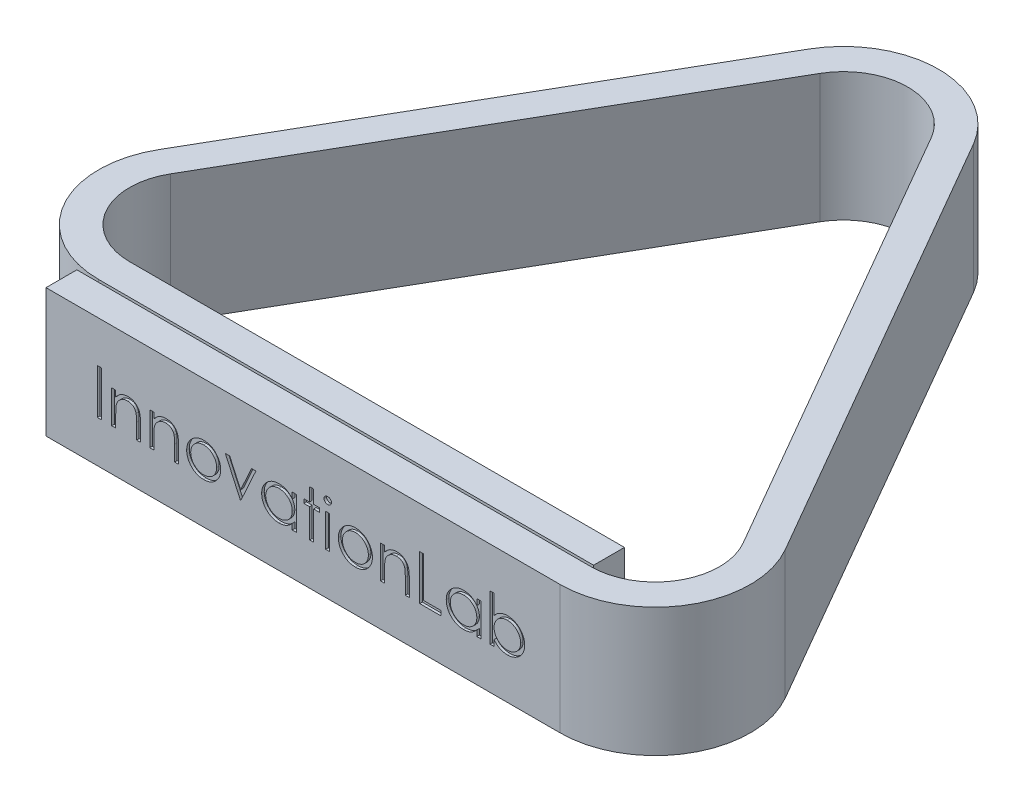
from build123d import *

# Parameters (mm, degrees)
BOSS_EXTRU_1_DEPTH      = 10
ESQUISSE2_W             = 0.314102564
ESQUISSE2_H             = 3.5
ESQUISSE2_H_2           = 2.557692307
ENL_V_MAT_EXTRU_1_DEPTH = 0.2


with BuildPart() as part:
    # Esquisse1 → Boss.-Extru.1 (new body)
    with BuildSketch(Plane(origin=(0, 0, 0), x_dir=(1, 0, 0), z_dir=(0, 1, 0))):
        with BuildLine():
            Line((0, 0), (40, 0))
            ThreePointArc((40, 0), (44.330127019, 2.5), (44.330127019, 7.5))
            Line((44.330127019, 7.5), (24.330127019, 42.141016151))
            ThreePointArc((24.330127019, 42.141016151), (20, 44.641016151), (15.669872981, 42.141016151))
            Line((15.669872981, 42.141016151), (-2.829016319, 10.1))
            ThreePointArc((-2.829016319, 10.1), (-2.829016319, 5.1), (1.5011107, 2.6))
            Line((1.5011107, 2.6), (40, 2.6))
            Line((40, 2.6), (40, 0.2))
            Line((40, 0.2), (1.5011107, 0.2))
            ThreePointArc((1.5011107, 0.2), (-4.907477288, 3.9), (-4.907477288, 11.3))
            Line((-4.907477288, 11.3), (13.591412012, 43.341016151))
            ThreePointArc((13.591412012, 43.341016151), (20, 47.041016151), (26.408587988, 43.341016151))
            Line((26.408587988, 43.341016151), (46.408587988, 8.7))
            ThreePointArc((46.408587988, 8.7), (46.408587988, 1.3), (40, -2.4))
            Line((40, -2.4), (0, -2.4))
            Line((0, -2.4), (0, 0))
        make_face()
    extrude(amount=BOSS_EXTRU_1_DEPTH)

    # Esquisse2 → Enlèv. mat.-Extru.1 (cut)
    with BuildSketch(Plane.XY.offset(2.4)):
        with Locations((4.146183367, 5.001354305)):
            Rectangle(ESQUISSE2_W, ESQUISSE2_H)
        with BuildLine():
            Line((5.110926957, 5.809046612), (5.425029521, 5.809046612))
            Line((5.425029521, 5.809046612), (5.425029521, 5.347708471))
            add(Edge.make_bspline(
                [(5.425029521, 5.347708471), (5.458567156, 5.389551194), (5.523648107, 5.470748458), (5.63203244, 5.577469032), (5.746576341, 5.665414257), (5.866578344, 5.735518051), (5.992201354, 5.788364677), (6.122679624, 5.826530609), (6.25879433, 5.849415437), (6.351358767, 5.852405667), (6.398186572, 5.853918407)],
                knots=[0, 0, 0, 0, 0.000160777, 0.000311994, 0.000455029, 0.000592958, 0.000727738, 0.000862858, 0.001000022, 0.001140458, 0.001140458, 0.001140458, 0.001140458], degree=3))
            add(Edge.make_bspline(
                [(6.398186572, 5.853918407), (6.445517206, 5.852173212), (6.538154674, 5.848757443), (6.673032735, 5.821740752), (6.799006129, 5.775595497), (6.915625685, 5.712383427), (7.020752898, 5.633776953), (7.11307775, 5.542199172), (7.189440997, 5.436863088), (7.24063836, 5.339139932), (7.274364008, 5.252451138), (7.295596345, 5.178204388), (7.313627327, 5.095486237), (7.329259075, 5.004546648), (7.339836187, 4.904748457), (7.348178478, 4.796500765), (7.354157172, 4.679838635), (7.354394379, 4.599152007), (7.3545167, 4.557544209)],
                knots=[0, 0, 0, 0, 0.00014192, 0.000277771, 0.000410631, 0.000543023, 0.000674273, 0.000803173, 0.000931629, 0.001063031, 0.00113295, 0.001210382, 0.001294414, 0.001386856, 0.001487045, 0.001595345, 0.001712567, 0.001837375, 0.001837375, 0.001837375, 0.001837375], degree=3))
            Line((7.3545167, 4.557544209), (7.3545167, 3.251354305))
            Line((7.3545167, 3.251354305), (7.040414136, 3.251354305))
            Line((7.040414136, 3.251354305), (7.040414136, 4.454479305))
            add(Edge.make_bspline(
                [(7.040414136, 4.454479305), (7.040220928, 4.48930175), (7.039851354, 4.55591116), (7.038685707, 4.651280184), (7.035875901, 4.737766762), (7.031927588, 4.815164129), (7.026148557, 4.883397966), (7.020125926, 4.942607243), (7.012760949, 4.992716785), (7.006198036, 5.022881868), (7.003254681, 5.036410394)],
                knots=[0, 0, 0, 0, 0.00010447, 0.000199832, 0.000286116, 0.000364054, 0.000432294, 0.000491525, 0.000542592, 0.000584118, 0.000584118, 0.000584118, 0.000584118], degree=3))
            add(Edge.make_bspline(
                [(7.003254681, 5.036410394), (6.99262915, 5.076121579), (6.972178289, 5.152553324), (6.921644306, 5.256227677), (6.857830125, 5.344425865), (6.779932276, 5.416602586), (6.6887032, 5.472773423), (6.584396057, 5.511747378), (6.468017417, 5.536123647), (6.386163034, 5.538550779), (6.343499072, 5.539815843)],
                knots=[0, 0, 0, 0, 0.000123096, 0.000236922, 0.000343781, 0.000447968, 0.000553428, 0.000663063, 0.000780492, 0.000908329, 0.000908329, 0.000908329, 0.000908329], degree=3))
            add(Edge.make_bspline(
                [(6.343499072, 5.539815843), (6.318231389, 5.539339839), (6.268227296, 5.538397838), (6.194077324, 5.52894654), (6.12215315, 5.513488084), (6.051732941, 5.492619446), (5.984225148, 5.463957177), (5.917460857, 5.431427807), (5.853954092, 5.390879595), (5.792350695, 5.345688974), (5.735037888, 5.295609766), (5.681709549, 5.242765256), (5.634171529, 5.186489652), (5.591102854, 5.127689705), (5.55392459, 5.065557867), (5.521471502, 5.00069356), (5.493935807, 4.933011412), (5.480253115, 4.88603635), (5.473406925, 4.862532189)],
                knots=[0, 0, 0, 0, 7.5773e-05, 0.000149953, 0.000223797, 0.000296325, 0.00036989, 0.000443574, 0.000518859, 0.000595564, 0.000672601, 0.000746967, 0.000820581, 0.000893366, 0.000965391, 0.001037508, 0.001110807, 0.001184211, 0.001184211, 0.001184211, 0.001184211], degree=3))
            add(Edge.make_bspline(
                [(5.473406925, 4.862532189), (5.469467276, 4.845276986), (5.460890867, 4.807713312), (5.451627687, 4.746068893), (5.443220112, 4.674758918), (5.436183153, 4.5938666), (5.431877737, 4.503108725), (5.42718334, 4.402872888), (5.425474279, 4.292759399), (5.425181925, 4.216097706), (5.425029521, 4.176133952)],
                knots=[0, 0, 0, 0, 5.3082e-05, 0.000115557, 0.000186868, 0.0002685, 0.000359077, 0.000459426, 0.000569522, 0.000689416, 0.000689416, 0.000689416, 0.000689416], degree=3))
            Line((5.425029521, 4.176133952), (5.425029521, 3.251354305))
            Line((5.425029521, 3.251354305), (5.110926957, 3.251354305))
            Line((5.110926957, 3.251354305), (5.110926957, 5.809046612))
        make_face()
        with BuildLine():
            Line((8.072465418, 5.809046612), (8.386567982, 5.809046612))
            Line((8.386567982, 5.809046612), (8.386567982, 5.347708471))
            add(Edge.make_bspline(
                [(8.386567982, 5.347708471), (8.420105618, 5.389551194), (8.485186569, 5.470748458), (8.593570902, 5.577469032), (8.708114802, 5.665414257), (8.828116806, 5.735518051), (8.953739816, 5.788364677), (9.084218086, 5.826530609), (9.220332792, 5.849415437), (9.312897229, 5.852405667), (9.359725034, 5.853918407)],
                knots=[0, 0, 0, 0, 0.000160777, 0.000311994, 0.000455029, 0.000592958, 0.000727738, 0.000862858, 0.001000022, 0.001140458, 0.001140458, 0.001140458, 0.001140458], degree=3))
            add(Edge.make_bspline(
                [(9.359725034, 5.853918407), (9.407055668, 5.852173212), (9.499693136, 5.848757443), (9.634571197, 5.821740752), (9.760544591, 5.775595497), (9.877164146, 5.712383427), (9.98229136, 5.633776953), (10.074616211, 5.542199172), (10.150979459, 5.436863088), (10.202176822, 5.339139932), (10.235902469, 5.252451138), (10.257134807, 5.178204388), (10.275165788, 5.095486237), (10.290797536, 5.004546648), (10.301374648, 4.904748457), (10.30971694, 4.796500765), (10.315695634, 4.679838635), (10.315932841, 4.599152007), (10.316055162, 4.557544209)],
                knots=[0, 0, 0, 0, 0.00014192, 0.000277771, 0.000410631, 0.000543023, 0.000674273, 0.000803173, 0.000931629, 0.001063031, 0.00113295, 0.001210382, 0.001294414, 0.001386856, 0.001487045, 0.001595345, 0.001712567, 0.001837375, 0.001837375, 0.001837375, 0.001837375], degree=3))
            Line((10.316055162, 4.557544209), (10.316055162, 3.251354305))
            Line((10.316055162, 3.251354305), (10.001952598, 3.251354305))
            Line((10.001952598, 3.251354305), (10.001952598, 4.454479305))
            add(Edge.make_bspline(
                [(10.001952598, 4.454479305), (10.00175939, 4.48930175), (10.001389816, 4.55591116), (10.000224169, 4.651280184), (9.997414362, 4.737766762), (9.99346605, 4.815164129), (9.987687019, 4.883397966), (9.981664388, 4.942607243), (9.974299411, 4.992716785), (9.967736498, 5.022881868), (9.964793143, 5.036410394)],
                knots=[0, 0, 0, 0, 0.00010447, 0.000199832, 0.000286116, 0.000364054, 0.000432294, 0.000491525, 0.000542592, 0.000584118, 0.000584118, 0.000584118, 0.000584118], degree=3))
            add(Edge.make_bspline(
                [(9.964793143, 5.036410394), (9.954167611, 5.076121579), (9.93371675, 5.152553324), (9.883182767, 5.256227677), (9.819368587, 5.344425865), (9.741470737, 5.416602586), (9.650241662, 5.472773423), (9.545934519, 5.511747378), (9.429555878, 5.536123647), (9.347701495, 5.538550779), (9.305037534, 5.539815843)],
                knots=[0, 0, 0, 0, 0.000123096, 0.000236922, 0.000343781, 0.000447968, 0.000553428, 0.000663063, 0.000780492, 0.000908329, 0.000908329, 0.000908329, 0.000908329], degree=3))
            add(Edge.make_bspline(
                [(9.305037534, 5.539815843), (9.27976985, 5.539339839), (9.229765757, 5.538397838), (9.155615785, 5.52894654), (9.083691612, 5.513488084), (9.013271403, 5.492619446), (8.945763609, 5.463957177), (8.878999318, 5.431427807), (8.815492554, 5.390879595), (8.753889157, 5.345688974), (8.696576349, 5.295609766), (8.643248011, 5.242765256), (8.595709991, 5.186489652), (8.552641315, 5.127689705), (8.515463052, 5.065557867), (8.483009964, 5.00069356), (8.455474269, 4.933011412), (8.441791577, 4.88603635), (8.434945386, 4.862532189)],
                knots=[0, 0, 0, 0, 7.5773e-05, 0.000149953, 0.000223797, 0.000296325, 0.00036989, 0.000443574, 0.000518859, 0.000595564, 0.000672601, 0.000746967, 0.000820581, 0.000893366, 0.000965391, 0.001037508, 0.001110807, 0.001184211, 0.001184211, 0.001184211, 0.001184211], degree=3))
            add(Edge.make_bspline(
                [(8.434945386, 4.862532189), (8.431005738, 4.845276986), (8.422429329, 4.807713312), (8.413166149, 4.746068893), (8.404758574, 4.674758918), (8.397721615, 4.5938666), (8.393416198, 4.503108725), (8.388721802, 4.402872888), (8.387012741, 4.292759399), (8.386720387, 4.216097706), (8.386567982, 4.176133952)],
                knots=[0, 0, 0, 0, 5.3082e-05, 0.000115557, 0.000186868, 0.0002685, 0.000359077, 0.000459426, 0.000569522, 0.000689416, 0.000689416, 0.000689416, 0.000689416], degree=3))
            Line((8.386567982, 4.176133952), (8.386567982, 3.251354305))
            Line((8.386567982, 3.251354305), (8.072465418, 3.251354305))
            Line((8.072465418, 3.251354305), (8.072465418, 5.809046612))
        make_face()
        with BuildLine():
            add(Edge.make_bspline(
                [(12.269380482, 5.853918407), (12.317371755, 5.852896516), (12.411470913, 5.850892837), (12.549278799, 5.829477872), (12.680823935, 5.796730507), (12.806610127, 5.751458945), (12.925026422, 5.690776995), (13.037797666, 5.618367704), (13.144614675, 5.53258511), (13.208637704, 5.466227042), (13.24113529, 5.432544209)],
                knots=[0, 0, 0, 0, 0.000143868, 0.000282091, 0.000417278, 0.000550139, 0.000682145, 0.000815559, 0.000951665, 0.001091969, 0.001091969, 0.001091969, 0.001091969], degree=3))
            add(Edge.make_bspline(
                [(13.24113529, 5.432544209), (13.269117244, 5.400330223), (13.324539624, 5.336525681), (13.395605343, 5.233070068), (13.456826903, 5.125929967), (13.505889864, 5.01368264), (13.544574888, 4.897307969), (13.572040584, 4.776405958), (13.588377519, 4.651243611), (13.590580486, 4.566239773), (13.591696188, 4.523189241)],
                knots=[0, 0, 0, 0, 0.000127922, 0.000253368, 0.000375813, 0.000497617, 0.000620225, 0.000743195, 0.000869033, 0.000998161, 0.000998161, 0.000998161, 0.000998161], degree=3))
            add(Edge.make_bspline(
                [(13.591696188, 4.523189241), (13.59071485, 4.479889183), (13.588775682, 4.39432625), (13.570432066, 4.268306884), (13.54190098, 4.146112061), (13.501069141, 4.028253367), (13.448711032, 3.91437054), (13.384820345, 3.804960991), (13.308948728, 3.699808857), (13.222944731, 3.599807019), (13.127892855, 3.507640804), (13.024776706, 3.427312535), (12.915622673, 3.35849101), (12.798979319, 3.303054595), (12.675911832, 3.259344895), (12.546154764, 3.228644878), (12.409909694, 3.210083194), (12.316882473, 3.207699621), (12.269380482, 3.20648251)],
                knots=[0, 0, 0, 0, 0.000129829, 0.000256548, 0.000381202, 0.000505812, 0.000630045, 0.000756669, 0.000885282, 0.001018518, 0.001151902, 0.001281775, 0.001409974, 0.001538236, 0.001668405, 0.001801048, 0.001937587, 0.002080055, 0.002080055, 0.002080055, 0.002080055], degree=3))
            add(Edge.make_bspline(
                [(12.269380482, 3.20648251), (12.221645763, 3.207703706), (12.128154903, 3.210095481), (11.991428921, 3.228572763), (11.861439302, 3.259330746), (11.738210704, 3.303198239), (11.621065857, 3.358492782), (11.51127936, 3.427104472), (11.408079444, 3.507664627), (11.31300746, 3.599800564), (11.227008855, 3.699810521), (11.151135846, 3.804960559), (11.08724552, 3.914370652), (11.034887316, 4.028253337), (10.994055503, 4.146112069), (10.965524411, 4.268306882), (10.947180796, 4.39432625), (10.945241628, 4.479889183), (10.94426029, 4.523189241)],
                knots=[0, 0, 0, 0, 0.000143168, 0.000280402, 0.000413045, 0.000543214, 0.000672108, 0.000800903, 0.000930775, 0.00106416, 0.001197395, 0.001326009, 0.001452632, 0.001576866, 0.001701476, 0.00182613, 0.001952849, 0.002082678, 0.002082678, 0.002082678, 0.002082678], degree=3))
            add(Edge.make_bspline(
                [(10.94426029, 4.523189241), (10.9453836, 4.566005787), (10.947607562, 4.650775189), (10.963928071, 4.77570225), (10.991286627, 4.896399639), (11.030018024, 5.012325115), (11.079533215, 5.124080551), (11.139894503, 5.231485382), (11.211685135, 5.334473182), (11.266887087, 5.398195262), (11.294821188, 5.430440843)],
                knots=[0, 0, 0, 0, 0.000128428, 0.000254265, 0.000377235, 0.000499178, 0.000620341, 0.000743397, 0.000868267, 0.000996189, 0.000996189, 0.000996189, 0.000996189], degree=3))
            add(Edge.make_bspline(
                [(11.294821188, 5.430440843), (11.327269779, 5.464415782), (11.391085642, 5.531233479), (11.49843437, 5.616766003), (11.610928191, 5.690682077), (11.730653117, 5.750158292), (11.856335975, 5.79699681), (11.988555218, 5.829562325), (12.126830733, 5.85081568), (12.221390354, 5.852873858), (12.269380482, 5.853918407)],
                knots=[0, 0, 0, 0, 0.000140798, 0.000276904, 0.000410699, 0.000543958, 0.000677061, 0.000812248, 0.000951858, 0.001095726, 0.001095726, 0.001095726, 0.001095726], degree=3))
        make_face()
        with BuildLine():
            add(Edge.make_bspline(
                [(12.267978239, 5.539815843), (12.234040627, 5.538851252), (12.167041499, 5.536946969), (12.068421914, 5.522463064), (11.97348176, 5.49951556), (11.882040916, 5.466911504), (11.794407744, 5.424812605), (11.710498341, 5.373104245), (11.630065901, 5.312471288), (11.554683838, 5.243008617), (11.485501526, 5.167129622), (11.425023549, 5.086281263), (11.373598443, 5.001774917), (11.330758284, 4.913522706), (11.298851096, 4.820630292), (11.275678073, 4.724149661), (11.261207833, 4.623884244), (11.259321454, 4.555723226), (11.258362854, 4.521085875)],
                knots=[0, 0, 0, 0, 0.000101781, 0.000200935, 0.000298373, 0.000394396, 0.000491609, 0.000589491, 0.000689611, 0.000793323, 0.000896562, 0.000997243, 0.001095722, 0.001192936, 0.001290943, 0.001389744, 0.001490285, 0.001594167, 0.001594167, 0.001594167, 0.001594167], degree=3))
            add(Edge.make_bspline(
                [(11.258362854, 4.521085875), (11.259969678, 4.476333848), (11.263158922, 4.387509443), (11.289094159, 4.25669832), (11.332480439, 4.131116468), (11.391067718, 4.011500082), (11.464473937, 3.900827804), (11.550961004, 3.802156319), (11.649600704, 3.716970508), (11.759217204, 3.646289662), (11.877571522, 3.590129907), (12.002827843, 3.550330931), (12.133468537, 3.524459239), (12.222749268, 3.521887764), (12.267978239, 3.520585074)],
                knots=[0, 0, 0, 0, 0.000134178, 0.000266319, 0.000398243, 0.00053182, 0.000664828, 0.000795487, 0.000924236, 0.001054533, 0.001185628, 0.001316003, 0.001448011, 0.001583547, 0.001583547, 0.001583547, 0.001583547], degree=3))
            add(Edge.make_bspline(
                [(12.267978239, 3.520585074), (12.313204608, 3.521895354), (12.402480204, 3.524481811), (12.532939381, 3.550200631), (12.657853352, 3.590304292), (12.77608474, 3.646226501), (12.885651343, 3.717238916), (12.985000465, 3.801675293), (13.070749076, 3.901089145), (13.144082681, 4.011646673), (13.203629423, 4.130931026), (13.246812625, 4.256721498), (13.272810211, 4.38750354), (13.27599104, 4.47633187), (13.277593623, 4.521085875)],
                knots=[0, 0, 0, 0, 0.000135536, 0.000267545, 0.000397252, 0.000528347, 0.000658644, 0.000787925, 0.000918122, 0.00105113, 0.001185017, 0.001316942, 0.001449082, 0.00158326, 0.00158326, 0.00158326, 0.00158326], degree=3))
            add(Edge.make_bspline(
                [(13.277593623, 4.521085875), (13.276635353, 4.555723433), (13.274749624, 4.623884859), (13.26027466, 4.724147312), (13.23711912, 4.820638909), (13.205147503, 4.913490912), (13.162493489, 5.002003416), (13.110076696, 5.086033144), (13.049845671, 5.16740969), (12.97982855, 5.24276333), (12.904525172, 5.312498367), (12.824060134, 5.373127756), (12.740275155, 5.424585352), (12.652896572, 5.467271592), (12.561444005, 5.499218933), (12.466636876, 5.522595564), (12.368438066, 5.536885761), (12.301679023, 5.538832902), (12.267978239, 5.539815843)],
                knots=[0, 0, 0, 0, 0.000103882, 0.000204424, 0.000303225, 0.000401232, 0.000498445, 0.000597291, 0.000697972, 0.000801684, 0.000905395, 0.001005516, 0.001103397, 0.001199979, 0.001296663, 0.00139342, 0.001492573, 0.001593654, 0.001593654, 0.001593654, 0.001593654], degree=3))
        make_face(mode=Mode.SUBTRACT)
        Polygon((13.950670547, 5.809046612), (14.290714617, 5.809046612), (15.139773111, 3.946867125), (15.988831604, 5.809046612), (16.328875675, 5.809046612), (15.162209008, 3.251354305), (15.117337213, 3.251354305), align=None)
        with BuildLine():
            Line((19.469901316, 5.809046612), (19.469901316, 3.251354305))
            Line((19.469901316, 3.251354305), (19.155798752, 3.251354305))
            Line((19.155798752, 3.251354305), (19.155798752, 3.693762157))
            add(Edge.make_bspline(
                [(19.155798752, 3.693762157), (19.120379961, 3.653722563), (19.051259746, 3.575584792), (18.935818628, 3.47350262), (18.81345045, 3.389124298), (18.684749129, 3.320974383), (18.549830885, 3.269782326), (18.408994798, 3.233396167), (18.262183417, 3.210002332), (18.161931062, 3.20766631), (18.111127277, 3.20648251)],
                knots=[0, 0, 0, 0, 0.000160263, 0.000312755, 0.000460949, 0.000605216, 0.000748578, 0.000892786, 0.001041028, 0.001193333, 0.001193333, 0.001193333, 0.001193333], degree=3))
            add(Edge.make_bspline(
                [(18.111127277, 3.20648251), (18.065959323, 3.207708882), (17.976886119, 3.210127343), (17.845857041, 3.228889646), (17.719764792, 3.259020268), (17.598490219, 3.300921157), (17.482818074, 3.356501979), (17.371757977, 3.423043227), (17.265885285, 3.502284057), (17.166813746, 3.592872085), (17.075581746, 3.691267073), (16.995520473, 3.796212619), (16.928767393, 3.907254923), (16.872947313, 4.022988077), (16.829950968, 4.144302997), (16.799977334, 4.270780165), (16.781236887, 4.402270038), (16.778819427, 4.491809561), (16.777593623, 4.537211677)],
                knots=[0, 0, 0, 0, 0.000135464, 0.00026714, 0.000396211, 0.000523931, 0.000651257, 0.000780517, 0.000911767, 0.001047265, 0.00118272, 0.001313831, 0.001442491, 0.001570752, 0.001698704, 0.001827775, 0.001960146, 0.00209631, 0.00209631, 0.00209631, 0.00209631], degree=3))
            add(Edge.make_bspline(
                [(16.777593623, 4.537211677), (16.778846595, 4.58167538), (16.781323652, 4.669577723), (16.799776871, 4.798856421), (16.83080788, 4.923374682), (16.874355728, 5.042731625), (16.930197683, 5.157071676), (16.99812577, 5.266475701), (17.078144894, 5.371245098), (17.170397302, 5.468916325), (17.270332072, 5.559136939), (17.377240803, 5.637545985), (17.488464084, 5.705262833), (17.605727094, 5.75891631), (17.727294199, 5.802325414), (17.854247645, 5.832358382), (17.986059224, 5.850055704), (18.075549716, 5.852618468), (18.120942982, 5.853918407)],
                knots=[0, 0, 0, 0, 0.000133363, 0.00026365, 0.000390846, 0.000517716, 0.000644083, 0.000771912, 0.000903449, 0.001038867, 0.001174416, 0.001306792, 0.001436052, 0.00156435, 0.001692963, 0.001822716, 0.001954992, 0.002091156, 0.002091156, 0.002091156, 0.002091156], degree=3))
            add(Edge.make_bspline(
                [(18.120942982, 5.853918407), (18.173142841, 5.852480656), (18.275504301, 5.849661293), (18.425232311, 5.826198566), (18.566876789, 5.786560098), (18.701531141, 5.7326426), (18.828711827, 5.660993871), (18.947214811, 5.57061391), (19.058280294, 5.462072723), (19.122660586, 5.378702279), (19.155798752, 5.335789401)],
                knots=[0, 0, 0, 0, 0.00015654, 0.000306968, 0.000453261, 0.000596998, 0.000741098, 0.000889738, 0.001042937, 0.001205434, 0.001205434, 0.001205434, 0.001205434], degree=3))
            Line((19.155798752, 5.335789401), (19.155798752, 5.809046612))
            Line((19.155798752, 5.809046612), (19.469901316, 5.809046612))
        make_face()
        with BuildLine():
            add(Edge.make_bspline(
                [(18.125149713, 5.539815843), (18.079235375, 5.538182205), (17.988607775, 5.534957664), (17.855563773, 5.509784169), (17.728250359, 5.467899575), (17.607304285, 5.410617674), (17.494636068, 5.338588937), (17.393942397, 5.251467554), (17.304399696, 5.15163054), (17.229091432, 5.039528429), (17.167700935, 4.919350338), (17.124533903, 4.7937259), (17.096064656, 4.664920923), (17.093156135, 4.577558237), (17.091696188, 4.533706068)],
                knots=[0, 0, 0, 0, 0.000137677, 0.000271753, 0.000404561, 0.000538791, 0.000672205, 0.000804452, 0.00093703, 0.001073348, 0.00120849, 0.001340643, 0.001470999, 0.001602378, 0.001602378, 0.001602378, 0.001602378], degree=3))
            add(Edge.make_bspline(
                [(17.091696188, 4.533706068), (17.093561081, 4.49011596), (17.097283558, 4.403106605), (17.124034252, 4.274126028), (17.168914126, 4.148471986), (17.230156188, 4.027210992), (17.306842813, 3.914626892), (17.395731466, 3.812886769), (17.497681747, 3.725397181), (17.610609254, 3.652159607), (17.731217224, 3.592997086), (17.858051156, 3.551831447), (17.988726794, 3.525253666), (18.077579128, 3.52214919), (18.122345226, 3.520585074)],
                knots=[0, 0, 0, 0, 0.000130727, 0.000260941, 0.000393327, 0.000530037, 0.000667328, 0.000800955, 0.000934191, 0.001068956, 0.001203792, 0.001335934, 0.001468075, 0.001602253, 0.001602253, 0.001602253, 0.001602253], degree=3))
            add(Edge.make_bspline(
                [(18.122345226, 3.520585074), (18.167791729, 3.522245038), (18.258180315, 3.525546542), (18.391619023, 3.550827807), (18.521113986, 3.592596605), (18.644901214, 3.650495732), (18.760217345, 3.722253088), (18.863715223, 3.806260179), (18.951231191, 3.903963363), (19.025423801, 4.011339816), (19.083599218, 4.129051812), (19.125975277, 4.254386003), (19.151029183, 4.387346751), (19.154186912, 4.478210678), (19.155798752, 4.524591484)],
                knots=[0, 0, 0, 0, 0.000136278, 0.000271043, 0.000405851, 0.000543552, 0.000679927, 0.000812429, 0.000941985, 0.001072088, 0.00120284, 0.001334538, 0.001467925, 0.001607002, 0.001607002, 0.001607002, 0.001607002], degree=3))
            add(Edge.make_bspline(
                [(19.155798752, 4.524591484), (19.154839095, 4.559929315), (19.152950188, 4.629485348), (19.138519618, 4.731612866), (19.115564692, 4.829346592), (19.083218522, 4.922789281), (19.040727237, 5.011424296), (18.989479472, 5.095888056), (18.928574022, 5.175741268), (18.858991326, 5.249884339), (18.782826123, 5.317510801), (18.702231583, 5.377875042), (18.616252836, 5.427463814), (18.526335799, 5.468505086), (18.432324464, 5.501164236), (18.333453844, 5.52295193), (18.230774857, 5.537912251), (18.160728802, 5.539174631), (18.125149713, 5.539815843)],
                knots=[0, 0, 0, 0, 0.000105983, 0.000208608, 0.000308773, 0.00040678, 0.000504626, 0.000603105, 0.000702667, 0.00080535, 0.000907651, 0.001007914, 0.001106881, 0.00120477, 0.001304102, 0.001404791, 0.00150811, 0.001614764, 0.001614764, 0.001614764, 0.001614764], degree=3))
        make_face(mode=Mode.SUBTRACT)
        Polygon((20.501952598, 6.841097894), (20.816055162, 6.841097894), (20.816055162, 5.809046612), (21.264773111, 5.809046612), (21.264773111, 5.494944048), (20.816055162, 5.494944048), (20.816055162, 3.251354305), (20.501952598, 3.251354305), (20.501952598, 5.494944048), (20.053234649, 5.494944048), (20.053234649, 5.809046612), (20.501952598, 5.809046612), align=None)
        with BuildLine():
            add(Edge.make_bspline(
                [(21.914011893, 6.885969689), (21.933503208, 6.885065537), (21.971670948, 6.883295033), (22.026864216, 6.868133556), (22.077121228, 6.84243387), (22.121698961, 6.807954189), (22.159950848, 6.767404746), (22.186731558, 6.720143778), (22.203943954, 6.669085139), (22.206022509, 6.63347005), (22.207080803, 6.615336677)],
                knots=[0, 0, 0, 0, 5.84e-05, 0.000114358, 0.000170171, 0.000226684, 0.000282761, 0.000336156, 0.000388483, 0.00044276, 0.00044276, 0.00044276, 0.00044276], degree=3))
            add(Edge.make_bspline(
                [(22.207080803, 6.615336677), (22.205998643, 6.597674023), (22.203859341, 6.562757048), (22.186744853, 6.512583576), (22.159722615, 6.465979293), (22.121723489, 6.425508583), (22.077114728, 6.391047963), (22.026865943, 6.365343224), (21.971670494, 6.350183086), (21.933503055, 6.348412398), (21.914011893, 6.347508151)],
                knots=[0, 0, 0, 0, 5.2882e-05, 0.000104542, 0.000157332, 0.000213408, 0.000269922, 0.000325735, 0.000381693, 0.000440092, 0.000440092, 0.000440092, 0.000440092], degree=3))
            add(Edge.make_bspline(
                [(21.914011893, 6.347508151), (21.894743617, 6.348377871), (21.857240437, 6.350070668), (21.802873595, 6.365640686), (21.753045106, 6.391056759), (21.708380433, 6.425282944), (21.67115024, 6.466227841), (21.644051914, 6.512555135), (21.626976953, 6.56276429), (21.624832324, 6.597676456), (21.62374747, 6.615336677)],
                knots=[0, 0, 0, 0, 5.7701e-05, 0.000112308, 0.000168121, 0.000224634, 0.000280239, 0.000333029, 0.000384689, 0.000437571, 0.000437571, 0.000437571, 0.000437571], degree=3))
            add(Edge.make_bspline(
                [(21.62374747, 6.615336677), (21.624808556, 6.633467526), (21.626892597, 6.669077659), (21.644064713, 6.720172692), (21.670924521, 6.767154193), (21.708405085, 6.808179693), (21.753038545, 6.842425128), (21.80287529, 6.867836109), (21.85723999, 6.883407449), (21.894743465, 6.885100063), (21.914011893, 6.885969689)],
                knots=[0, 0, 0, 0, 5.4277e-05, 0.000106603, 0.000159999, 0.000215605, 0.000272118, 0.000327931, 0.000382538, 0.000440239, 0.000440239, 0.000440239, 0.000440239], degree=3))
        make_face()
        with Locations((21.915414136, 4.530200459)):
            Rectangle(ESQUISSE2_W, ESQUISSE2_H_2)
        with BuildLine():
            add(Edge.make_bspline(
                [(24.070662534, 5.853918407), (24.118653807, 5.852896516), (24.212752964, 5.850892837), (24.35056085, 5.829477872), (24.482105986, 5.796730507), (24.607892178, 5.751458945), (24.726308474, 5.690776995), (24.839079718, 5.618367704), (24.945896727, 5.53258511), (25.009919756, 5.466227042), (25.042417341, 5.432544209)],
                knots=[0, 0, 0, 0, 0.000143868, 0.000282091, 0.000417278, 0.000550139, 0.000682145, 0.000815559, 0.000951665, 0.001091969, 0.001091969, 0.001091969, 0.001091969], degree=3))
            add(Edge.make_bspline(
                [(25.042417341, 5.432544209), (25.070399295, 5.400330223), (25.125821676, 5.336525681), (25.196887394, 5.233070068), (25.258108955, 5.125929967), (25.307171916, 5.01368264), (25.345856939, 4.897307969), (25.373322636, 4.776405958), (25.38965957, 4.651243611), (25.391862537, 4.566239773), (25.392978239, 4.523189241)],
                knots=[0, 0, 0, 0, 0.000127922, 0.000253368, 0.000375813, 0.000497617, 0.000620225, 0.000743195, 0.000869033, 0.000998161, 0.000998161, 0.000998161, 0.000998161], degree=3))
            add(Edge.make_bspline(
                [(25.392978239, 4.523189241), (25.391996901, 4.479889183), (25.390057733, 4.39432625), (25.371714117, 4.268306884), (25.343183031, 4.146112061), (25.302351193, 4.028253367), (25.249993083, 3.91437054), (25.186102396, 3.804960991), (25.110230779, 3.699808857), (25.024226782, 3.599807019), (24.929174906, 3.507640804), (24.826058758, 3.427312535), (24.716904724, 3.35849101), (24.600261371, 3.303054595), (24.477193884, 3.259344895), (24.347436816, 3.228644878), (24.211191745, 3.210083194), (24.118164524, 3.207699621), (24.070662534, 3.20648251)],
                knots=[0, 0, 0, 0, 0.000129829, 0.000256548, 0.000381202, 0.000505812, 0.000630045, 0.000756669, 0.000885282, 0.001018518, 0.001151902, 0.001281775, 0.001409974, 0.001538236, 0.001668405, 0.001801048, 0.001937587, 0.002080055, 0.002080055, 0.002080055, 0.002080055], degree=3))
            add(Edge.make_bspline(
                [(24.070662534, 3.20648251), (24.022927814, 3.207703706), (23.929436954, 3.210095481), (23.792710973, 3.228572763), (23.662721354, 3.259330746), (23.539492755, 3.303198239), (23.422347908, 3.358492782), (23.312561411, 3.427104472), (23.209361496, 3.507664627), (23.114289511, 3.599800564), (23.028290906, 3.699810521), (22.952417898, 3.804960559), (22.888527571, 3.914370652), (22.836169368, 4.028253337), (22.795337555, 4.146112069), (22.766806462, 4.268306882), (22.748462847, 4.39432625), (22.746523679, 4.479889183), (22.745542341, 4.523189241)],
                knots=[0, 0, 0, 0, 0.000143168, 0.000280402, 0.000413045, 0.000543214, 0.000672108, 0.000800903, 0.000930775, 0.00106416, 0.001197395, 0.001326009, 0.001452632, 0.001576866, 0.001701476, 0.00182613, 0.001952849, 0.002082678, 0.002082678, 0.002082678, 0.002082678], degree=3))
            add(Edge.make_bspline(
                [(22.745542341, 4.523189241), (22.746665652, 4.566005787), (22.748889613, 4.650775189), (22.765210122, 4.77570225), (22.792568679, 4.896399639), (22.831300075, 5.012325115), (22.880815266, 5.124080551), (22.941176554, 5.231485382), (23.012967187, 5.334473182), (23.068169138, 5.398195262), (23.096103239, 5.430440843)],
                knots=[0, 0, 0, 0, 0.000128428, 0.000254265, 0.000377235, 0.000499178, 0.000620341, 0.000743397, 0.000868267, 0.000996189, 0.000996189, 0.000996189, 0.000996189], degree=3))
            add(Edge.make_bspline(
                [(23.096103239, 5.430440843), (23.12855183, 5.464415782), (23.192367694, 5.531233479), (23.299716421, 5.616766003), (23.412210243, 5.690682077), (23.531935169, 5.750158292), (23.657618027, 5.79699681), (23.789837269, 5.829562325), (23.928112785, 5.85081568), (24.022672406, 5.852873858), (24.070662534, 5.853918407)],
                knots=[0, 0, 0, 0, 0.000140798, 0.000276904, 0.000410699, 0.000543958, 0.000677061, 0.000812248, 0.000951858, 0.001095726, 0.001095726, 0.001095726, 0.001095726], degree=3))
        make_face()
        with BuildLine():
            add(Edge.make_bspline(
                [(24.06926029, 5.539815843), (24.035322679, 5.538851252), (23.96832355, 5.536946969), (23.869703965, 5.522463064), (23.774763811, 5.49951556), (23.683322967, 5.466911504), (23.595689795, 5.424812605), (23.511780393, 5.373104245), (23.431347953, 5.312471288), (23.355965889, 5.243008617), (23.286783577, 5.167129622), (23.2263056, 5.086281263), (23.174880494, 5.001774917), (23.132040335, 4.913522706), (23.100133147, 4.820630292), (23.076960125, 4.724149661), (23.062489884, 4.623884244), (23.060603506, 4.555723226), (23.059644905, 4.521085875)],
                knots=[0, 0, 0, 0, 0.000101781, 0.000200935, 0.000298373, 0.000394396, 0.000491609, 0.000589491, 0.000689611, 0.000793323, 0.000896562, 0.000997243, 0.001095722, 0.001192936, 0.001290943, 0.001389744, 0.001490285, 0.001594167, 0.001594167, 0.001594167, 0.001594167], degree=3))
            add(Edge.make_bspline(
                [(23.059644905, 4.521085875), (23.061251729, 4.476333848), (23.064440974, 4.387509443), (23.09037621, 4.25669832), (23.13376249, 4.131116468), (23.19234977, 4.011500082), (23.265755988, 3.900827804), (23.352243055, 3.802156319), (23.450882755, 3.716970508), (23.560499256, 3.646289662), (23.678853573, 3.590129907), (23.804109895, 3.550330931), (23.934750589, 3.524459239), (24.02403132, 3.521887764), (24.06926029, 3.520585074)],
                knots=[0, 0, 0, 0, 0.000134178, 0.000266319, 0.000398243, 0.00053182, 0.000664828, 0.000795487, 0.000924236, 0.001054533, 0.001185628, 0.001316003, 0.001448011, 0.001583547, 0.001583547, 0.001583547, 0.001583547], degree=3))
            add(Edge.make_bspline(
                [(24.06926029, 3.520585074), (24.114486659, 3.521895354), (24.203762255, 3.524481811), (24.334221432, 3.550200631), (24.459135404, 3.590304292), (24.577366791, 3.646226501), (24.686933395, 3.717238916), (24.786282516, 3.801675293), (24.872031127, 3.901089145), (24.945364732, 4.011646673), (25.004911475, 4.130931026), (25.048094677, 4.256721498), (25.074092262, 4.38750354), (25.077273091, 4.47633187), (25.078875675, 4.521085875)],
                knots=[0, 0, 0, 0, 0.000135536, 0.000267545, 0.000397252, 0.000528347, 0.000658644, 0.000787925, 0.000918122, 0.00105113, 0.001185017, 0.001316942, 0.001449082, 0.00158326, 0.00158326, 0.00158326, 0.00158326], degree=3))
            add(Edge.make_bspline(
                [(25.078875675, 4.521085875), (25.077917405, 4.555723433), (25.076031676, 4.623884859), (25.061556711, 4.724147312), (25.038401172, 4.820638909), (25.006429554, 4.913490912), (24.96377554, 5.002003416), (24.911358747, 5.086033144), (24.851127722, 5.16740969), (24.781110601, 5.24276333), (24.705807223, 5.312498367), (24.625342185, 5.373127756), (24.541557206, 5.424585352), (24.454178624, 5.467271592), (24.362726056, 5.499218933), (24.267918927, 5.522595564), (24.169720117, 5.536885761), (24.102961074, 5.538832902), (24.06926029, 5.539815843)],
                knots=[0, 0, 0, 0, 0.000103882, 0.000204424, 0.000303225, 0.000401232, 0.000498445, 0.000597291, 0.000697972, 0.000801684, 0.000905395, 0.001005516, 0.001103397, 0.001199979, 0.001296663, 0.00139342, 0.001492573, 0.001593654, 0.001593654, 0.001593654, 0.001593654], degree=3))
        make_face(mode=Mode.SUBTRACT)
        with BuildLine():
            Line((26.021183367, 5.809046612), (26.335285931, 5.809046612))
            Line((26.335285931, 5.809046612), (26.335285931, 5.347708471))
            add(Edge.make_bspline(
                [(26.335285931, 5.347708471), (26.368823566, 5.389551194), (26.433904517, 5.470748458), (26.542288851, 5.577469032), (26.656832751, 5.665414257), (26.776834754, 5.735518051), (26.902457764, 5.788364677), (27.032936034, 5.826530609), (27.169050741, 5.849415437), (27.261615177, 5.852405667), (27.308442982, 5.853918407)],
                knots=[0, 0, 0, 0, 0.000160777, 0.000311994, 0.000455029, 0.000592958, 0.000727738, 0.000862858, 0.001000022, 0.001140458, 0.001140458, 0.001140458, 0.001140458], degree=3))
            add(Edge.make_bspline(
                [(27.308442982, 5.853918407), (27.355773617, 5.852173212), (27.448411084, 5.848757443), (27.583289146, 5.821740752), (27.709262539, 5.775595497), (27.825882095, 5.712383427), (27.931009308, 5.633776953), (28.02333416, 5.542199172), (28.099697407, 5.436863088), (28.15089477, 5.339139932), (28.184620418, 5.252451138), (28.205852756, 5.178204388), (28.223883737, 5.095486237), (28.239515485, 5.004546648), (28.250092597, 4.904748457), (28.258434888, 4.796500765), (28.264413583, 4.679838635), (28.26465079, 4.599152007), (28.264773111, 4.557544209)],
                knots=[0, 0, 0, 0, 0.00014192, 0.000277771, 0.000410631, 0.000543023, 0.000674273, 0.000803173, 0.000931629, 0.001063031, 0.00113295, 0.001210382, 0.001294414, 0.001386856, 0.001487045, 0.001595345, 0.001712567, 0.001837375, 0.001837375, 0.001837375, 0.001837375], degree=3))
            Line((28.264773111, 4.557544209), (28.264773111, 3.251354305))
            Line((28.264773111, 3.251354305), (27.950670547, 3.251354305))
            Line((27.950670547, 3.251354305), (27.950670547, 4.454479305))
            add(Edge.make_bspline(
                [(27.950670547, 4.454479305), (27.950477338, 4.48930175), (27.950107764, 4.55591116), (27.948942118, 4.651280184), (27.946132311, 4.737766762), (27.942183998, 4.815164129), (27.936404968, 4.883397966), (27.930382336, 4.942607243), (27.92301736, 4.992716785), (27.916454446, 5.022881868), (27.913511091, 5.036410394)],
                knots=[0, 0, 0, 0, 0.00010447, 0.000199832, 0.000286116, 0.000364054, 0.000432294, 0.000491525, 0.000542592, 0.000584118, 0.000584118, 0.000584118, 0.000584118], degree=3))
            add(Edge.make_bspline(
                [(27.913511091, 5.036410394), (27.90288556, 5.076121579), (27.882434699, 5.152553324), (27.831900716, 5.256227677), (27.768086535, 5.344425865), (27.690188686, 5.416602586), (27.59895961, 5.472773423), (27.494652468, 5.511747378), (27.378273827, 5.536123647), (27.296419444, 5.538550779), (27.253755482, 5.539815843)],
                knots=[0, 0, 0, 0, 0.000123096, 0.000236922, 0.000343781, 0.000447968, 0.000553428, 0.000663063, 0.000780492, 0.000908329, 0.000908329, 0.000908329, 0.000908329], degree=3))
            add(Edge.make_bspline(
                [(27.253755482, 5.539815843), (27.228487799, 5.539339839), (27.178483706, 5.538397838), (27.104333734, 5.52894654), (27.032409561, 5.513488084), (26.961989352, 5.492619446), (26.894481558, 5.463957177), (26.827717267, 5.431427807), (26.764210503, 5.390879595), (26.702607106, 5.345688974), (26.645294298, 5.295609766), (26.591965959, 5.242765256), (26.544427939, 5.186489652), (26.501359264, 5.127689705), (26.464181001, 5.065557867), (26.431727913, 5.00069356), (26.404192218, 4.933011412), (26.390509525, 4.88603635), (26.383663335, 4.862532189)],
                knots=[0, 0, 0, 0, 7.5773e-05, 0.000149953, 0.000223797, 0.000296325, 0.00036989, 0.000443574, 0.000518859, 0.000595564, 0.000672601, 0.000746967, 0.000820581, 0.000893366, 0.000965391, 0.001037508, 0.001110807, 0.001184211, 0.001184211, 0.001184211, 0.001184211], degree=3))
            add(Edge.make_bspline(
                [(26.383663335, 4.862532189), (26.379723686, 4.845276986), (26.371147278, 4.807713312), (26.361884098, 4.746068893), (26.353476522, 4.674758918), (26.346439564, 4.5938666), (26.342134147, 4.503108725), (26.33743975, 4.402872888), (26.335730689, 4.292759399), (26.335438335, 4.216097706), (26.335285931, 4.176133952)],
                knots=[0, 0, 0, 0, 5.3082e-05, 0.000115557, 0.000186868, 0.0002685, 0.000359077, 0.000459426, 0.000569522, 0.000689416, 0.000689416, 0.000689416, 0.000689416], degree=3))
            Line((26.335285931, 4.176133952), (26.335285931, 3.251354305))
            Line((26.335285931, 3.251354305), (26.021183367, 3.251354305))
            Line((26.021183367, 3.251354305), (26.021183367, 5.809046612))
        make_face()
        Polygon((29.072465418, 6.751354305), (29.386567982, 6.751354305), (29.386567982, 3.610328664), (30.732721829, 3.610328664), (30.732721829, 3.251354305), (29.072465418, 3.251354305), align=None)
        with BuildLine():
            Line((33.828875675, 5.809046612), (33.828875675, 3.251354305))
            Line((33.828875675, 3.251354305), (33.514773111, 3.251354305))
            Line((33.514773111, 3.251354305), (33.514773111, 3.693762157))
            add(Edge.make_bspline(
                [(33.514773111, 3.693762157), (33.47935432, 3.653722563), (33.410234105, 3.575584792), (33.294792987, 3.47350262), (33.172424809, 3.389124298), (33.043723488, 3.320974383), (32.908805244, 3.269782326), (32.767969157, 3.233396167), (32.621157776, 3.210002332), (32.520905421, 3.20766631), (32.470101636, 3.20648251)],
                knots=[0, 0, 0, 0, 0.000160263, 0.000312755, 0.000460949, 0.000605216, 0.000748578, 0.000892786, 0.001041028, 0.001193333, 0.001193333, 0.001193333, 0.001193333], degree=3))
            add(Edge.make_bspline(
                [(32.470101636, 3.20648251), (32.424933682, 3.207708882), (32.335860478, 3.210127343), (32.2048314, 3.228889646), (32.078739151, 3.259020268), (31.957464578, 3.300921157), (31.841792433, 3.356501979), (31.730732336, 3.423043227), (31.624859644, 3.502284057), (31.525788105, 3.592872085), (31.434556105, 3.691267073), (31.354494832, 3.796212619), (31.287741752, 3.907254923), (31.231921672, 4.022988077), (31.188925327, 4.144302997), (31.158951693, 4.270780165), (31.140211246, 4.402270038), (31.137793786, 4.491809561), (31.136567982, 4.537211677)],
                knots=[0, 0, 0, 0, 0.000135464, 0.00026714, 0.000396211, 0.000523931, 0.000651257, 0.000780517, 0.000911767, 0.001047265, 0.00118272, 0.001313831, 0.001442491, 0.001570752, 0.001698704, 0.001827775, 0.001960146, 0.00209631, 0.00209631, 0.00209631, 0.00209631], degree=3))
            add(Edge.make_bspline(
                [(31.136567982, 4.537211677), (31.137820954, 4.58167538), (31.140298011, 4.669577723), (31.15875123, 4.798856421), (31.189782239, 4.923374682), (31.233330087, 5.042731625), (31.289172042, 5.157071676), (31.357100129, 5.266475701), (31.437119253, 5.371245098), (31.52937166, 5.468916325), (31.629306431, 5.559136939), (31.736215162, 5.637545985), (31.847438443, 5.705262833), (31.964701453, 5.75891631), (32.086268558, 5.802325414), (32.213222004, 5.832358382), (32.345033583, 5.850055704), (32.434524075, 5.852618468), (32.479917341, 5.853918407)],
                knots=[0, 0, 0, 0, 0.000133363, 0.00026365, 0.000390846, 0.000517716, 0.000644083, 0.000771912, 0.000903449, 0.001038867, 0.001174416, 0.001306792, 0.001436052, 0.00156435, 0.001692963, 0.001822716, 0.001954992, 0.002091156, 0.002091156, 0.002091156, 0.002091156], degree=3))
            add(Edge.make_bspline(
                [(32.479917341, 5.853918407), (32.5321172, 5.852480656), (32.63447866, 5.849661293), (32.78420667, 5.826198566), (32.925851148, 5.786560098), (33.0605055, 5.7326426), (33.187686186, 5.660993871), (33.30618917, 5.57061391), (33.417254653, 5.462072723), (33.481634945, 5.378702279), (33.514773111, 5.335789401)],
                knots=[0, 0, 0, 0, 0.00015654, 0.000306968, 0.000453261, 0.000596998, 0.000741098, 0.000889738, 0.001042937, 0.001205434, 0.001205434, 0.001205434, 0.001205434], degree=3))
            Line((33.514773111, 5.335789401), (33.514773111, 5.809046612))
            Line((33.514773111, 5.809046612), (33.828875675, 5.809046612))
        make_face()
        with BuildLine():
            add(Edge.make_bspline(
                [(32.484124072, 5.539815843), (32.438209734, 5.538182205), (32.347582134, 5.534957664), (32.214538132, 5.509784169), (32.087224718, 5.467899575), (31.966278644, 5.410617674), (31.853610427, 5.338588937), (31.752916756, 5.251467554), (31.663374055, 5.15163054), (31.588065791, 5.039528429), (31.526675294, 4.919350338), (31.483508262, 4.7937259), (31.455039015, 4.664920923), (31.452130494, 4.577558237), (31.450670547, 4.533706068)],
                knots=[0, 0, 0, 0, 0.000137677, 0.000271753, 0.000404561, 0.000538791, 0.000672205, 0.000804452, 0.00093703, 0.001073348, 0.00120849, 0.001340643, 0.001470999, 0.001602378, 0.001602378, 0.001602378, 0.001602378], degree=3))
            add(Edge.make_bspline(
                [(31.450670547, 4.533706068), (31.45253544, 4.49011596), (31.456257917, 4.403106605), (31.483008611, 4.274126028), (31.527888485, 4.148471986), (31.589130547, 4.027210992), (31.665817172, 3.914626892), (31.754705825, 3.812886769), (31.856656106, 3.725397181), (31.969583613, 3.652159607), (32.090191583, 3.592997086), (32.217025515, 3.551831447), (32.347701153, 3.525253666), (32.436553487, 3.52214919), (32.481319585, 3.520585074)],
                knots=[0, 0, 0, 0, 0.000130727, 0.000260941, 0.000393327, 0.000530037, 0.000667328, 0.000800955, 0.000934191, 0.001068956, 0.001203792, 0.001335934, 0.001468075, 0.001602253, 0.001602253, 0.001602253, 0.001602253], degree=3))
            add(Edge.make_bspline(
                [(32.481319585, 3.520585074), (32.526766088, 3.522245038), (32.617154674, 3.525546542), (32.750593382, 3.550827807), (32.880088345, 3.592596605), (33.003875573, 3.650495732), (33.119191704, 3.722253088), (33.222689582, 3.806260179), (33.31020555, 3.903963363), (33.38439816, 4.011339816), (33.442573577, 4.129051812), (33.484949636, 4.254386003), (33.510003542, 4.387346751), (33.513161271, 4.478210678), (33.514773111, 4.524591484)],
                knots=[0, 0, 0, 0, 0.000136278, 0.000271043, 0.000405851, 0.000543552, 0.000679927, 0.000812429, 0.000941985, 0.001072088, 0.00120284, 0.001334538, 0.001467925, 0.001607002, 0.001607002, 0.001607002, 0.001607002], degree=3))
            add(Edge.make_bspline(
                [(33.514773111, 4.524591484), (33.513813454, 4.559929315), (33.511924547, 4.629485348), (33.497493977, 4.731612866), (33.474539051, 4.829346592), (33.442192881, 4.922789281), (33.399701596, 5.011424296), (33.348453831, 5.095888056), (33.287548381, 5.175741268), (33.217965685, 5.249884339), (33.141800482, 5.317510801), (33.061205942, 5.377875042), (32.975227195, 5.427463814), (32.885310158, 5.468505086), (32.791298823, 5.501164236), (32.692428203, 5.52295193), (32.589749216, 5.537912251), (32.519703161, 5.539174631), (32.484124072, 5.539815843)],
                knots=[0, 0, 0, 0, 0.000105983, 0.000208608, 0.000308773, 0.00040678, 0.000504626, 0.000603105, 0.000702667, 0.00080535, 0.000907651, 0.001007914, 0.001106881, 0.00120477, 0.001304102, 0.001404791, 0.00150811, 0.001614764, 0.001614764, 0.001614764, 0.001614764], degree=3))
        make_face(mode=Mode.SUBTRACT)
        with BuildLine():
            Line((34.546824393, 3.251354305), (34.546824393, 6.841097894))
            Line((34.546824393, 6.841097894), (34.860926957, 6.841097894))
            Line((34.860926957, 6.841097894), (34.860926957, 5.344903984))
            add(Edge.make_bspline(
                [(34.860926957, 5.344903984), (34.896320376, 5.385661916), (34.965374395, 5.465182321), (35.081150846, 5.569029971), (35.202556416, 5.657082449), (35.330514672, 5.729668567), (35.465207605, 5.784942174), (35.605939714, 5.825364564), (35.753070754, 5.849751467), (35.853389928, 5.85251754), (35.904196188, 5.853918407)],
                knots=[0, 0, 0, 0, 0.000161815, 0.000315708, 0.000465351, 0.000611017, 0.000755934, 0.000901068, 0.001049529, 0.001201867, 0.001201867, 0.001201867, 0.001201867], degree=3))
            add(Edge.make_bspline(
                [(35.904196188, 5.853918407), (35.949362325, 5.852678179), (36.038663477, 5.850226037), (36.169945624, 5.831591541), (36.2962589, 5.801373739), (36.417534547, 5.75948156), (36.53320668, 5.703898583), (36.644265737, 5.637357275), (36.750142721, 5.558118946), (36.849197607, 5.467520635), (36.940491493, 5.369164012), (37.020404003, 5.263983697), (37.087903699, 5.153508607), (37.143734992, 5.038108544), (37.186906045, 4.917312193), (37.216648312, 4.791237994), (37.235541776, 4.660009976), (37.237922023, 4.570697172), (37.239132085, 4.525292606)],
                knots=[0, 0, 0, 0, 0.000135464, 0.000267835, 0.000396906, 0.000524625, 0.000651952, 0.000781211, 0.000912462, 0.00104796, 0.001183414, 0.001314526, 0.001443549, 0.001571179, 0.00169847, 0.001827542, 0.001959218, 0.002095382, 0.002095382, 0.002095382, 0.002095382], degree=3))
            add(Edge.make_bspline(
                [(37.239132085, 4.525292606), (37.237895644, 4.480592588), (37.235457578, 4.392451193), (37.21683627, 4.262744637), (37.186090006, 4.137905938), (37.142128822, 4.01825768), (37.086863884, 3.903237767), (37.017752608, 3.794157363), (36.937941609, 3.689118387), (36.84561046, 3.591494756), (36.745696907, 3.501261356), (36.638782664, 3.422855491), (36.527560743, 3.355138371), (36.41029763, 3.301482923), (36.288729589, 3.258082002), (36.161554202, 3.227964311), (36.029490974, 3.210391256), (35.939772086, 3.207795689), (35.894380482, 3.20648251)],
                knots=[0, 0, 0, 0, 0.000134063, 0.000264351, 0.000392226, 0.000519096, 0.000646094, 0.000774294, 0.000905831, 0.001041249, 0.001176798, 0.001309174, 0.001438434, 0.001566731, 0.001695345, 0.001825098, 0.001958069, 0.002094233, 0.002094233, 0.002094233, 0.002094233], degree=3))
            add(Edge.make_bspline(
                [(35.894380482, 3.20648251), (35.84241537, 3.207923118), (35.740520846, 3.2107479), (35.591468181, 3.234166879), (35.450386631, 3.274028489), (35.315669083, 3.327590245), (35.18924136, 3.400118899), (35.070300777, 3.490075649), (34.959597405, 3.598942786), (34.894380589, 3.682004275), (34.860926957, 3.724611516)],
                knots=[0, 0, 0, 0, 0.00015584, 0.000305575, 0.000451192, 0.000594929, 0.000739376, 0.000887033, 0.001041224, 0.001203621, 0.001203621, 0.001203621, 0.001203621], degree=3))
            Line((34.860926957, 3.724611516), (34.860926957, 3.251354305))
            Line((34.860926957, 3.251354305), (34.546824393, 3.251354305))
        make_face()
        with BuildLine():
            add(Edge.make_bspline(
                [(35.891575995, 3.520585074), (35.937490348, 3.522218703), (36.028117977, 3.525443226), (36.161161767, 3.55061685), (36.288475977, 3.592500963), (36.409419059, 3.649784672), (36.522098371, 3.721806707), (36.622751005, 3.808952877), (36.712230714, 3.908454392), (36.78688249, 4.020688085), (36.849208735, 4.140139054), (36.892022011, 4.265793356), (36.920741732, 4.394288145), (36.923594031, 4.481434189), (36.925029521, 4.525292606)],
                knots=[0, 0, 0, 0, 0.000137677, 0.000271753, 0.000404561, 0.000538791, 0.000672205, 0.000804452, 0.00093703, 0.001072374, 0.001207834, 0.001339988, 0.001469657, 0.001601037, 0.001601037, 0.001601037, 0.001601037], degree=3))
            add(Edge.make_bspline(
                [(36.925029521, 4.525292606), (36.923141777, 4.569108148), (36.919373826, 4.656564309), (36.892999043, 4.786213976), (36.846941253, 4.911801601), (36.78582323, 5.032979589), (36.709955245, 5.14598739), (36.620949281, 5.247477517), (36.519067475, 5.335037501), (36.406244055, 5.408027572), (36.286063865, 5.467587125), (36.159573231, 5.508432151), (36.029415108, 5.535170338), (35.941019616, 5.538259466), (35.896483848, 5.539815843)],
                knots=[0, 0, 0, 0, 0.000131426, 0.000262328, 0.000394949, 0.000531659, 0.000668557, 0.000802185, 0.00093542, 0.001070185, 0.001204391, 0.001336533, 0.001467986, 0.001601464, 0.001601464, 0.001601464, 0.001601464], degree=3))
            add(Edge.make_bspline(
                [(35.896483848, 5.539815843), (35.85101634, 5.538260346), (35.760772564, 5.535172999), (35.627604342, 5.508385175), (35.497541058, 5.467337563), (35.373253526, 5.408406214), (35.257399471, 5.336294754), (35.153786858, 5.251554554), (35.064455301, 5.154774646), (34.99091153, 5.046268844), (34.932506731, 4.929083809), (34.890722983, 4.804071606), (34.865723336, 4.671890293), (34.862545204, 4.581257087), (34.860926957, 4.535108311)],
                knots=[0, 0, 0, 0, 0.000136278, 0.000270483, 0.00040596, 0.000544592, 0.000681933, 0.000814436, 0.000944937, 0.001075619, 0.00120637, 0.001336516, 0.001469903, 0.00160828, 0.00160828, 0.00160828, 0.00160828], degree=3))
            add(Edge.make_bspline(
                [(34.860926957, 4.535108311), (34.861886627, 4.499770493), (34.863775562, 4.430214483), (34.878205931, 4.328086793), (34.901161593, 4.2303537), (34.933505087, 4.136908705), (34.976006321, 4.048282265), (35.027216587, 3.963786185), (35.088168233, 3.884182907), (35.157074823, 3.809667586), (35.233037204, 3.741858172), (35.314560322, 3.683079947), (35.399978253, 3.632465757), (35.490268224, 3.592120914), (35.584379514, 3.559194394), (35.683277856, 3.537460648), (35.78594928, 3.522485609), (35.855996377, 3.521225256), (35.891575995, 3.520585074)],
                knots=[0, 0, 0, 0, 0.000105983, 0.000208608, 0.000308773, 0.00040678, 0.000504626, 0.000603105, 0.000702667, 0.000804872, 0.000907174, 0.001007588, 0.001105951, 0.001204477, 0.001303809, 0.001404498, 0.001507818, 0.001614471, 0.001614471, 0.001614471, 0.001614471], degree=3))
        make_face(mode=Mode.SUBTRACT)
    extrude(amount=-ENL_V_MAT_EXTRU_1_DEPTH, mode=Mode.SUBTRACT)


solid = part.part
